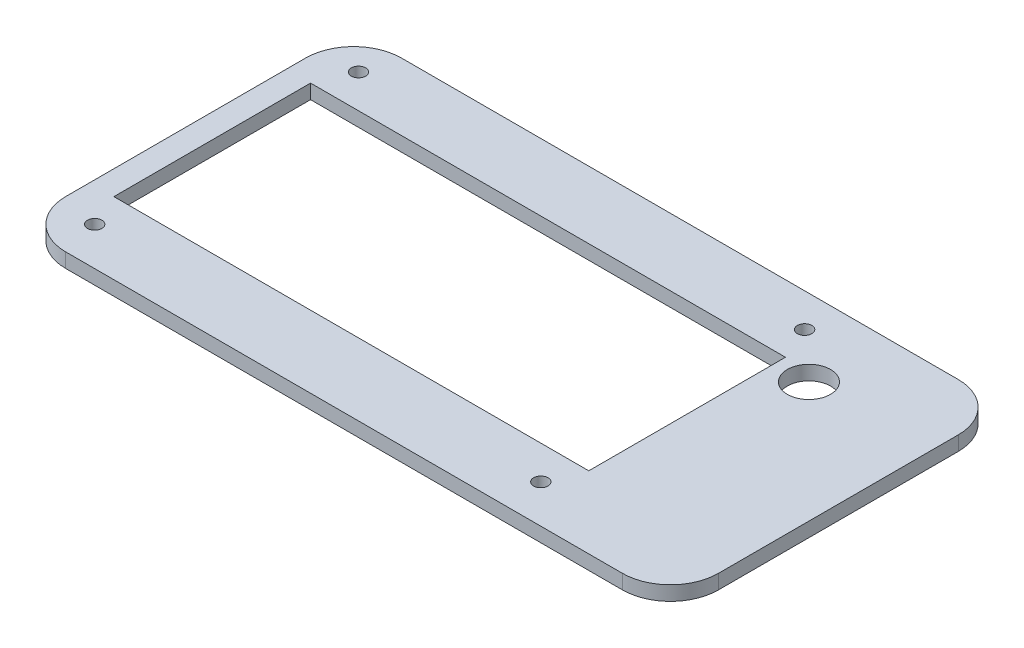
from build123d import *

# Parameters (mm, degrees)
SKETCH1_R           = 1.5
SKETCH1_R_2         = 4.5
SKETCH1_W           = 99
SKETCH1_H           = 41
BOSS_EXTRUDE1_DEPTH = 3


with BuildPart() as part:
    # Sketch1 → Boss-Extrude1 (new body)
    with BuildSketch(Plane(origin=(0, 0, 0), x_dir=(1, 0, 0), z_dir=(0, 1, 0))):
        with BuildLine():
            Line((69.094938721, -38.021047238), (69.094938721, 11.978952762))
            ThreePointArc((69.094938721, 11.978952762), (66.166006532, 19.050020574), (59.094938721, 21.978952762))
            Line((59.094938721, 21.978952762), (-56.968320128, 21.978952762))
            ThreePointArc((-56.968320128, 21.978952762), (-64.039387939, 19.050020574), (-66.968320128, 11.978952762))
            Line((-66.968320128, 11.978952762), (-66.968320128, -38.021047238))
            ThreePointArc((-66.968320128, -38.021047238), (-64.039387939, -45.09211505), (-56.968320128, -48.021047238))
            Line((-56.968320128, -48.021047238), (59.094938721, -48.021047238))
            ThreePointArc((59.094938721, -48.021047238), (66.166006532, -45.09211505), (69.094938721, -38.021047238))
        make_face()
        with Locations((-58.93171984, 14.978952762)):
            Circle(SKETCH1_R, mode=Mode.SUBTRACT)
        with Locations((34.06828016, 14.978952762)):
            Circle(SKETCH1_R, mode=Mode.SUBTRACT)
        with Locations((-58.93171984, -40.021047238)):
            Circle(SKETCH1_R, mode=Mode.SUBTRACT)
        with Locations((34.06828016, -40.021047238)):
            Circle(SKETCH1_R, mode=Mode.SUBTRACT)
        with Locations((43.96828016, 5.978952762)):
            Circle(SKETCH1_R_2, mode=Mode.SUBTRACT)
        with Locations((-12.43171984, -12.521047238)):
            Rectangle(SKETCH1_W, SKETCH1_H, mode=Mode.SUBTRACT)
    extrude(amount=BOSS_EXTRUDE1_DEPTH)


solid = part.part
